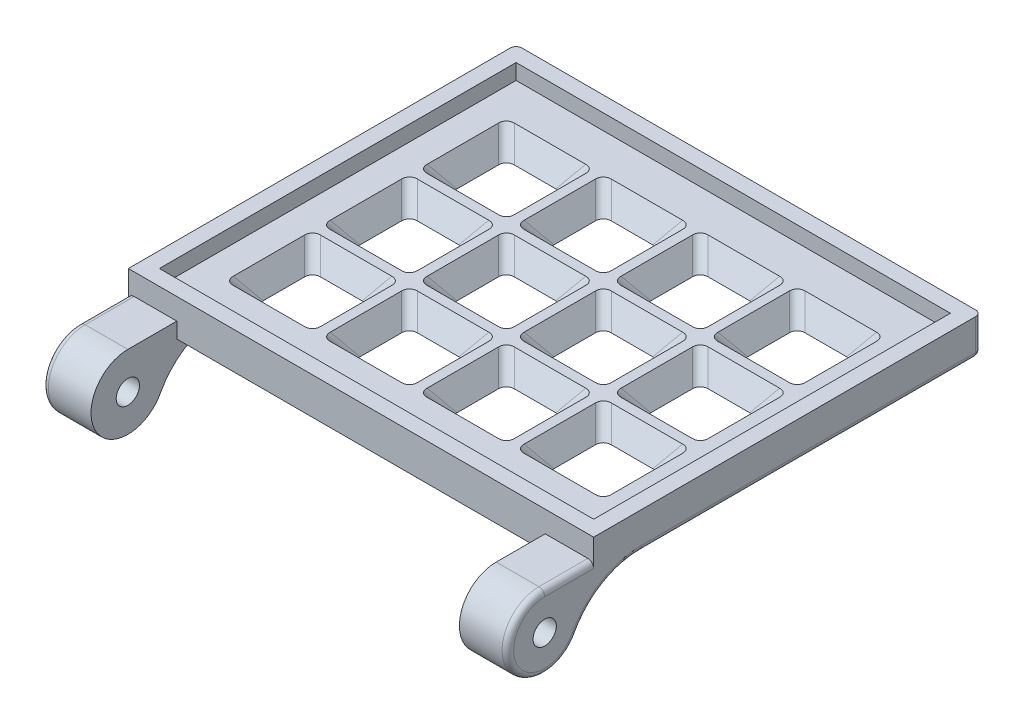
from build123d import *

# Parameters (mm, degrees)
SKETCH1_W              = 60.96
SKETCH1_H              = 50.8
BOSS_EXTRUDE1_DEPTH    = 3.048
SKETCH2_W              = 11.43
SKETCH2_H              = 11.43
CUT_EXTRUDE1_DEPTH     = 3.048
CUT_EXTRUDE1_TAPER     = 35
FILLET1_R              = 1.27
LPATTERN1_COUNT        = 4
LPATTERN1_PITCH        = 12.7
LPATTERN1_COUNT_DIR2   = 3
LPATTERN1_PITCH_DIR2   = 12.7
FILLET1_OF_LPATTERN1_R = 1.27
SKETCH9_W              = 60.96
SKETCH9_H              = 50.8
SKETCH9_W_2            = 56.896
SKETCH9_H_2            = 46.736
BOSS_EXTRUDE2_DEPTH    = 2.032
SKETCH11_W             = 60.96
SKETCH11_H             = 55.88
CUT_EXTRUDE3_DEPTH     = 0.254
SKETCH14_R             = 1.524
BOSS_EXTRUDE3_DEPTH    = 6.35
BOSS_EXTRUDE4_DEPTH    = 6.35
FILLET9_R              = 0.762


with BuildPart() as part:
    # Sketch1 → Boss-Extrude1 (new body)
    with BuildSketch(Plane(origin=(0, 0, 0), x_dir=(1, 0, 0), z_dir=(0, 1, 0))):
        Rectangle(SKETCH1_W, SKETCH1_H)
    extrude(amount=BOSS_EXTRUDE1_DEPTH)

    # Sketch2 → Cut-Extrude1 (cut)
    with BuildSketch(Plane(origin=(0, 3.048, 0), x_dir=(1, 0, 0), z_dir=(0, 1, 0))):
        with Locations((-19.05, 12.7)):
            Rectangle(SKETCH2_W, SKETCH2_H)
    cut_extrude1 = extrude(amount=-CUT_EXTRUDE1_DEPTH, taper=CUT_EXTRUDE1_TAPER, mode=Mode.SUBTRACT)

    # Fillet1
    fillet1_edges = [part.edges().sort_by_distance(p)[0] for p in [
        (-14.402116288, 1.524, -17.347883712),
        (-14.402116288, 1.524, -8.052116288),
        (-23.697883712, 1.524, -8.052116288),
        (-23.697883712, 1.524, -17.347883712),
    ]]
    fillet(fillet1_edges, radius=FILLET1_R)

    # LPattern1: Cut-Extrude1 4 × 3
    with Locations(*[(i * LPATTERN1_PITCH, 0, j * LPATTERN1_PITCH_DIR2) for i in range(LPATTERN1_COUNT) for j in range(LPATTERN1_COUNT_DIR2) if (i, j) != (0, 0)]):
        add(cut_extrude1, mode=Mode.SUBTRACT)

    # Fillet1 of LPattern1
    fillet1_of_lpattern1_edges = [part.edges().sort_by_distance(p)[0] for p in [
        (-14.402116288, 1.524, -4.647883712),
        (-14.402116288, 1.524, 4.647883712),
        (-23.697883712, 1.524, 4.647883712),
        (-23.697883712, 1.524, -4.647883712),
        (-14.402116288, 1.524, 8.052116288),
        (-14.402116288, 1.524, 17.347883712),
        (-23.697883712, 1.524, 17.347883712),
        (-23.697883712, 1.524, 8.052116288),
        (-1.702116288, 1.524, -17.347883712),
        (-1.702116288, 1.524, -8.052116288),
        (-10.997883712, 1.524, -8.052116288),
        (-10.997883712, 1.524, -17.347883712),
        (-1.702116288, 1.524, -4.647883712),
        (-1.702116288, 1.524, 4.647883712),
        (-10.997883712, 1.524, 4.647883712),
        (-10.997883712, 1.524, -4.647883712),
        (-1.702116288, 1.524, 8.052116288),
        (-1.702116288, 1.524, 17.347883712),
        (-10.997883712, 1.524, 17.347883712),
        (-10.997883712, 1.524, 8.052116288),
        (10.997883712, 1.524, -17.347883712),
        (10.997883712, 1.524, -8.052116288),
        (1.702116288, 1.524, -8.052116288),
        (1.702116288, 1.524, -17.347883712),
        (10.997883712, 1.524, -4.647883712),
        (10.997883712, 1.524, 4.647883712),
        (1.702116288, 1.524, 4.647883712),
        (1.702116288, 1.524, -4.647883712),
        (10.997883712, 1.524, 8.052116288),
        (10.997883712, 1.524, 17.347883712),
        (1.702116288, 1.524, 17.347883712),
        (1.702116288, 1.524, 8.052116288),
        (23.697883712, 1.524, -17.347883712),
        (23.697883712, 1.524, -8.052116288),
        (14.402116288, 1.524, -8.052116288),
        (14.402116288, 1.524, -17.347883712),
        (23.697883712, 1.524, -4.647883712),
        (23.697883712, 1.524, 4.647883712),
        (14.402116288, 1.524, 4.647883712),
        (14.402116288, 1.524, -4.647883712),
        (23.697883712, 1.524, 8.052116288),
        (23.697883712, 1.524, 17.347883712),
        (14.402116288, 1.524, 17.347883712),
        (14.402116288, 1.524, 8.052116288),
    ]]
    fillet(fillet1_of_lpattern1_edges, radius=FILLET1_OF_LPATTERN1_R)

    # Sketch9 → Boss-Extrude2 (add)
    with BuildSketch(Plane(origin=(0, 3.048, 0), x_dir=(1, 0, 0), z_dir=(0, 1, 0))):
        Rectangle(SKETCH9_W, SKETCH9_H)
        Rectangle(SKETCH9_W_2, SKETCH9_H_2, mode=Mode.SUBTRACT)
    extrude(amount=BOSS_EXTRUDE2_DEPTH)

    # Sketch11 → Cut-Extrude3 (cut)
    with BuildSketch(Plane.XZ):
        with Locations((0, -2.54)):
            Rectangle(SKETCH11_W, SKETCH11_H)
    extrude(amount=-CUT_EXTRUDE3_DEPTH, mode=Mode.SUBTRACT)

    # Sketch14 → Boss-Extrude3 (add)
    with BuildSketch(Plane(origin=(30.48, 0, 0), x_dir=(0, 0, -1), z_dir=(1, 0, 0))):
        with BuildLine():
            Line((-25.4, 2.286), (-31.8135, 2.286))
            ThreePointArc((-31.8135, 2.286), (-35.225997326, -5.952497326), (-26.9875, -2.54))
            Line((-26.9875, -2.54), (-26.9875, 0.254))
            Line((-26.9875, 0.254), (-25.4, 0.254))
            Line((-25.4, 0.254), (-23.368, 0.254))
            Line((-23.368, 0.254), (-23.368, 2.286))
            Line((-23.368, 2.286), (-25.4, 2.286))
        make_face()
        with Locations((-31.8135, -2.54)):
            Circle(SKETCH14_R, mode=Mode.SUBTRACT)
    boss_extrude3 = extrude(amount=-BOSS_EXTRUDE3_DEPTH)

    # Sketch15 → Boss-Extrude4 (add)
    with BuildSketch(Plane(origin=(30.48, 3.048, 25.4), x_dir=(0, 0, -1), z_dir=(1, 0, 0))):
        with BuildLine():
            Line((6.2822829, -2.794), (-1.5875, -2.794))
            Line((-1.5875, -2.794), (-2.154599329, -7.857810802))
            ThreePointArc((-2.154599329, -7.857810802), (1.362344852, -4.157132071), (6.2822829, -2.794))
        make_face()
    boss_extrude4 = extrude(amount=-BOSS_EXTRUDE4_DEPTH)

    # Mirror3: Boss-Extrude3, Boss-Extrude4 across plane
    add(boss_extrude3.mirror(Plane.ZY))
    add(boss_extrude4.mirror(Plane.ZY))

    # Fillet9
    fillet9_edges = [part.edges().sort_by_distance(p)[0] for p in [
        (30.48, 0.254, -3.14114145),
        (0, 0.254, -25.4),
        (30.48, 2.286, 28.60675),
        (30.48, -5.023562871, 35.951396986),
        (30.48, -1.109132071, 24.037655148),
        (-30.48, 2.286, 28.60675),
        (-30.48, -5.023562871, 35.951396986),
        (-30.48, 0.254, -3.14114145),
        (-30.48, -1.109132071, 24.037655148),
        (-30.48, 2.667, -25.4),
        (30.48, 2.667, -25.4),
    ]]
    fillet(fillet9_edges, radius=FILLET9_R)


solid = part.part
